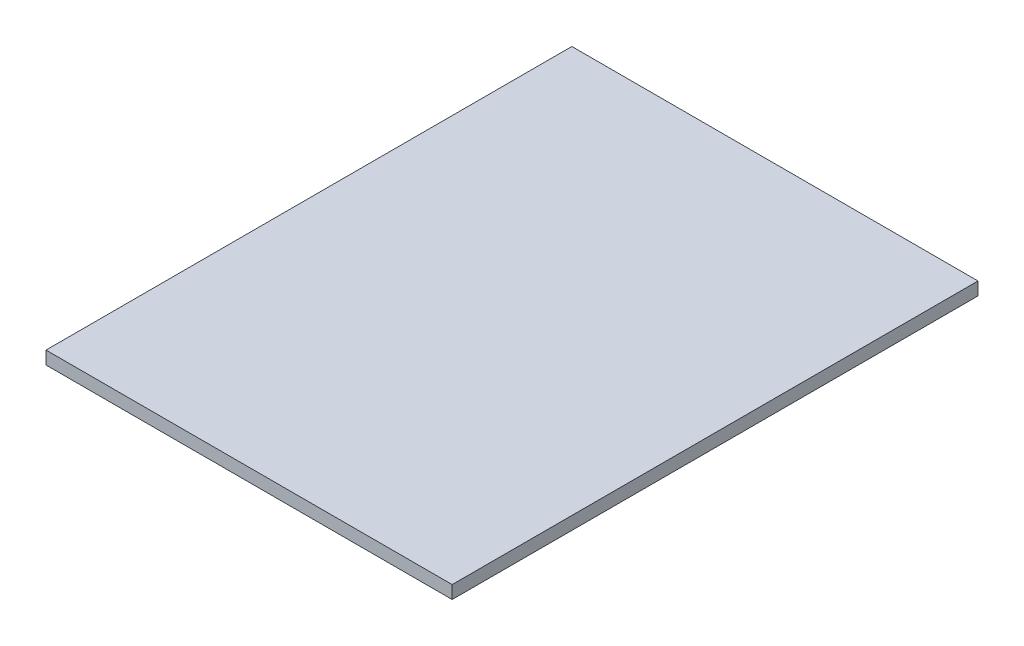
from build123d import *

# Parameters (mm, degrees)
SKETCH1_W           = 517.4488
SKETCH1_H           = 669.925
BOSS_EXTRUDE1_DEPTH = 19.05
CHAMFER1_SIZE       = 2.54


with BuildPart() as part:
    # Sketch1 → Boss-Extrude1 (new body)
    with BuildSketch(Plane(origin=(0, 0, 0), x_dir=(1, 0, 0), z_dir=(0, 1, 0))):
        with Locations((258.7244, 334.9625)):
            Rectangle(SKETCH1_W, SKETCH1_H)
    extrude(amount=BOSS_EXTRUDE1_DEPTH)

    # Chamfer1
    chamfer1_edges = [part.edges().sort_by_distance(p)[0] for p in [
        (258.7244, 0, -669.925),
        (517.4488, 0, -334.9625),
        (258.7244, 0, 0),
        (0, 0, -334.9625),
    ]]
    chamfer(chamfer1_edges, length=CHAMFER1_SIZE)


solid = part.part
